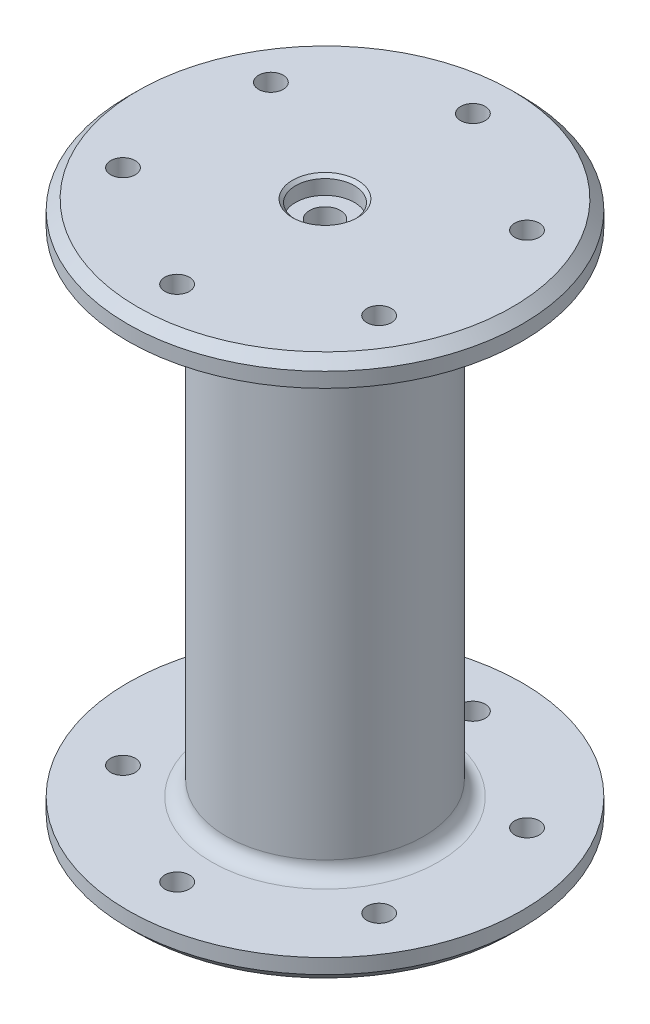
from build123d import *

# Parameters (mm, degrees)
SKETCH1_R                = 20
BOSS_EXTRUDE1_DEPTH      = 50
SKETCH2_R                = 40
BOSS_EXTRUDE2_DEPTH      = 5
CHAMFER1_SIZE            = 2
CUT_EXTRUDE1_START       = -295
SKETCH3_R                = 2.5
CUT_EXTRUDE1_DEPTH       = 690
CIRPATTERN1_COUNT        = 6
FILLET1_R                = 3
CUT_EXTRUDE2_START       = -102.4186
SKETCH6_R                = 3.125
CUT_EXTRUDE2_DEPTH       = 107
CHAMFER1_OF_MIRROR3_SIZE = 2
FILLET1_OF_MIRROR3_R     = 3
MIRROR4_START            = -295
MIRROR4_COPY_1_SKETCH_R  = 2.5
MIRROR4_COPY_1_DEPTH     = 690
MIRROR4_COPY_2_SKETCH_R  = 2.5
MIRROR4_COPY_2_DEPTH     = 690
MIRROR4_COPY_3_SKETCH_R  = 2.5
MIRROR4_COPY_3_DEPTH     = 690
MIRROR4_COPY_4_SKETCH_R  = 2.5
MIRROR4_COPY_4_DEPTH     = 690
MIRROR4_COPY_5_SKETCH_R  = 2.5
MIRROR4_COPY_5_DEPTH     = 690


with BuildPart() as part:
    # Sketch1 → Boss-Extrude1 (new body, symmetric)
    with BuildSketch(Plane(origin=(0, 0, 0), x_dir=(1, 0, 0), z_dir=(0, 1, 0))):
        Circle(SKETCH1_R)
    extrude(amount=BOSS_EXTRUDE1_DEPTH, both=True)

    # Sketch2 → Boss-Extrude2 (add)
    with BuildSketch(Plane(origin=(0, 50, 0), x_dir=(1, 0, 0), z_dir=(0, 1, 0))):
        Circle(SKETCH2_R)
    boss_extrude2 = extrude(amount=BOSS_EXTRUDE2_DEPTH)

    # Chamfer1
    chamfer1_edges = [part.edges().sort_by_distance(p)[0] for p in [
        (-40, 55, 0),
    ]]
    chamfer(chamfer1_edges, length=CHAMFER1_SIZE)

    # Sketch3 → Cut-Extrude1 (cut)
    with BuildSketch(Plane(origin=(0, 55, 0), x_dir=(1, 0, 0), z_dir=(0, 1, 0)).offset(CUT_EXTRUDE1_START)):
        with Locations((0, 30)):
            Circle(SKETCH3_R)
    cut_extrude1 = extrude(amount=CUT_EXTRUDE1_DEPTH, mode=Mode.SUBTRACT)

    # CirPattern1: Cut-Extrude1 ×6 about axis
    cirpattern1_axis = Axis((0, 0, 0), (0, 1, 0))
    for i in range(1, CIRPATTERN1_COUNT):
        add(cut_extrude1.rotate(cirpattern1_axis, i * 360 / CIRPATTERN1_COUNT), mode=Mode.SUBTRACT)

    # Fillet1
    fillet1_edges = [part.edges().sort_by_distance(p)[0] for p in [
        (-20, 50, 0),
    ]]
    fillet(fillet1_edges, radius=FILLET1_R)

    # Sketch5 → CBORE for #12 Binding Head Machine Screw1 (revolve, cut)
    with BuildSketch(Plane(origin=(0, 55, 0), x_dir=(0, 0, 1), z_dir=(1, 0, 0))):
        Polygon((0, 0), (0, 1.927208746), (3.1242, 0.05), (3.1242, 3.5814), (5.95376, 3.5814), (5.95376, 0.635), (6.58876, 0), align=None)
    cbore_for_12_binding_head_machine_screw = revolve(axis=Axis((0, 61.35, 0), (0, -1, 0)), mode=Mode.SUBTRACT)

    # Sketch6 → Cut-Extrude2 (cut)
    with BuildSketch(Plane(origin=(0, 51.4186, 0), x_dir=(1, 0, 0), z_dir=(0, 1, 0)).offset(CUT_EXTRUDE2_START)):
        Circle(SKETCH6_R)
    cut_extrude2 = extrude(amount=CUT_EXTRUDE2_DEPTH, mode=Mode.SUBTRACT)

    # Mirror3: Boss-Extrude2, CBORE for #12 Binding Head Machine Screw1, Cut-Extrude2 across plane
    add(boss_extrude2.mirror(Plane.ZX))
    add(cbore_for_12_binding_head_machine_screw.mirror(Plane.ZX), mode=Mode.SUBTRACT)
    add(cut_extrude2.mirror(Plane.ZX), mode=Mode.SUBTRACT)

    # Chamfer1 of Mirror3
    chamfer1_of_mirror3_edges = [part.edges().sort_by_distance(p)[0] for p in [
        (-40, -55, 0),
    ]]
    chamfer(chamfer1_of_mirror3_edges, length=CHAMFER1_OF_MIRROR3_SIZE)

    # Fillet1 of Mirror3
    fillet1_of_mirror3_edges = [part.edges().sort_by_distance(p)[0] for p in [
        (-20, -50, 0),
    ]]
    fillet(fillet1_of_mirror3_edges, radius=FILLET1_OF_MIRROR3_R)

    # Mirror4: Cut-Extrude1 across plane
    add(cut_extrude1.mirror(Plane.ZX), mode=Mode.SUBTRACT)

    # Mirror4 copy 1 sketch → Mirror4 copy 1 (cut)
    with BuildSketch(Plane(origin=(0, -55, 0), x_dir=(0.5, 0, -0.866025404), z_dir=(0, -1, 0)).offset(MIRROR4_START)):
        with Locations((0, -30)):
            Circle(MIRROR4_COPY_1_SKETCH_R)
    extrude(amount=MIRROR4_COPY_1_DEPTH, mode=Mode.SUBTRACT)

    # Mirror4 copy 2 sketch → Mirror4 copy 2 (cut)
    with BuildSketch(Plane(origin=(0, -55, 0), x_dir=(-0.5, 0, -0.866025404), z_dir=(0, -1, 0)).offset(MIRROR4_START)):
        with Locations((0, -30)):
            Circle(MIRROR4_COPY_2_SKETCH_R)
    extrude(amount=MIRROR4_COPY_2_DEPTH, mode=Mode.SUBTRACT)

    # Mirror4 copy 3 sketch → Mirror4 copy 3 (cut)
    with BuildSketch(Plane(origin=(0, -55, 0), x_dir=(-1, 0, 0), z_dir=(0, -1, 0)).offset(MIRROR4_START)):
        with Locations((0, -30)):
            Circle(MIRROR4_COPY_3_SKETCH_R)
    extrude(amount=MIRROR4_COPY_3_DEPTH, mode=Mode.SUBTRACT)

    # Mirror4 copy 4 sketch → Mirror4 copy 4 (cut)
    with BuildSketch(Plane(origin=(0, -55, 0), x_dir=(-0.5, 0, 0.866025404), z_dir=(0, -1, 0)).offset(MIRROR4_START)):
        with Locations((0, -30)):
            Circle(MIRROR4_COPY_4_SKETCH_R)
    extrude(amount=MIRROR4_COPY_4_DEPTH, mode=Mode.SUBTRACT)

    # Mirror4 copy 5 sketch → Mirror4 copy 5 (cut)
    with BuildSketch(Plane(origin=(0, -55, 0), x_dir=(0.5, 0, 0.866025404), z_dir=(0, -1, 0)).offset(MIRROR4_START)):
        with Locations((0, -30)):
            Circle(MIRROR4_COPY_5_SKETCH_R)
    extrude(amount=MIRROR4_COPY_5_DEPTH, mode=Mode.SUBTRACT)


solid = part.part
